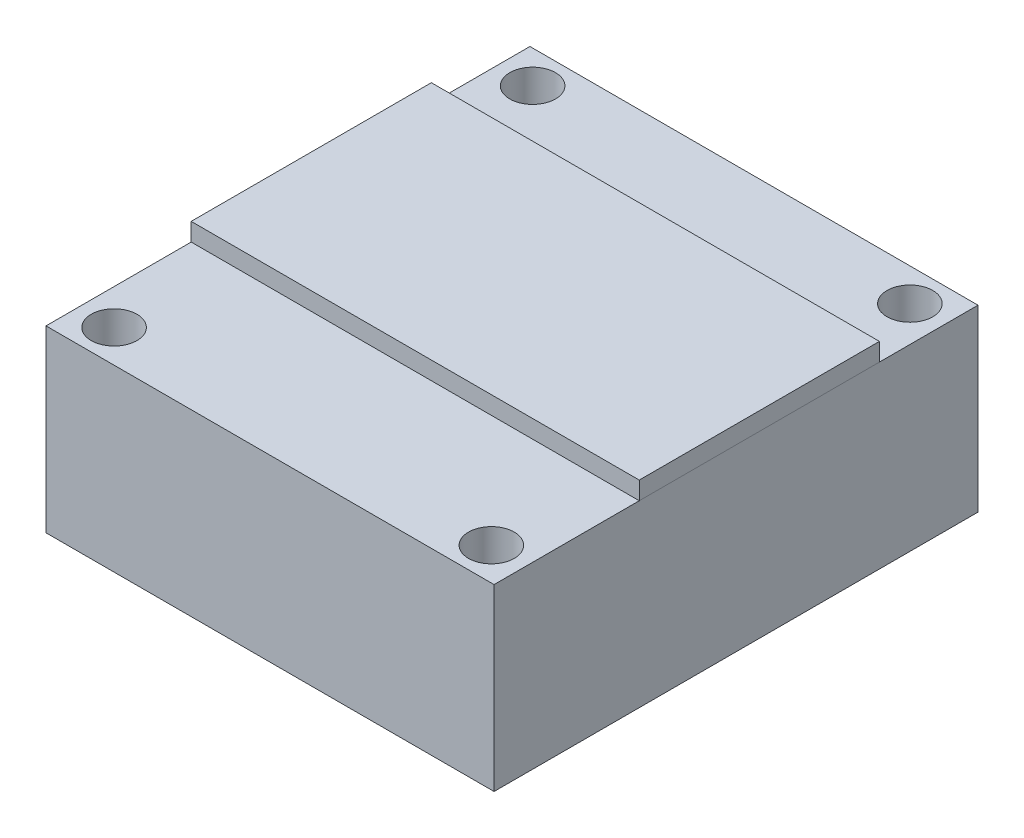
from build123d import *

# Parameters (mm, degrees)
SKETCH1_W           = 25
SKETCH1_H           = 27
SKETCH1_R           = 1.275
BOSS_EXTRUDE1_DEPTH = 10
SKETCH2_W           = 25
SKETCH2_H           = 13.4
BOSS_EXTRUDE2_DEPTH = 1


with BuildPart() as part:
    # Sketch1 → Boss-Extrude1 (new body)
    with BuildSketch(Plane(origin=(0, 0, 0), x_dir=(1, 0, 0), z_dir=(0, 1, 0))):
        with Locations((64.659126964, -28.384601034)):
            Rectangle(SKETCH1_W, SKETCH1_H)
        with Locations((54.134126964, -16.709601034)):
            Circle(SKETCH1_R, mode=Mode.SUBTRACT)
        with Locations((54.134126964, -40.059601034)):
            Circle(SKETCH1_R, mode=Mode.SUBTRACT)
        with Locations((75.184126964, -40.059601034)):
            Circle(SKETCH1_R, mode=Mode.SUBTRACT)
        with Locations((75.184126964, -16.709601034)):
            Circle(SKETCH1_R, mode=Mode.SUBTRACT)
    extrude(amount=BOSS_EXTRUDE1_DEPTH)


with BuildPart() as body_2:
    # Sketch2 → Boss-Extrude2 (new body)
    with BuildSketch(Plane(origin=(0, 10, 0), x_dir=(1, 0, 0), z_dir=(0, 1, 0))):
        with Locations((64.659126964, -27.084601034)):
            Rectangle(SKETCH2_W, SKETCH2_H)
    extrude(amount=BOSS_EXTRUDE2_DEPTH)


solid = Compound([part.part, body_2.part])
